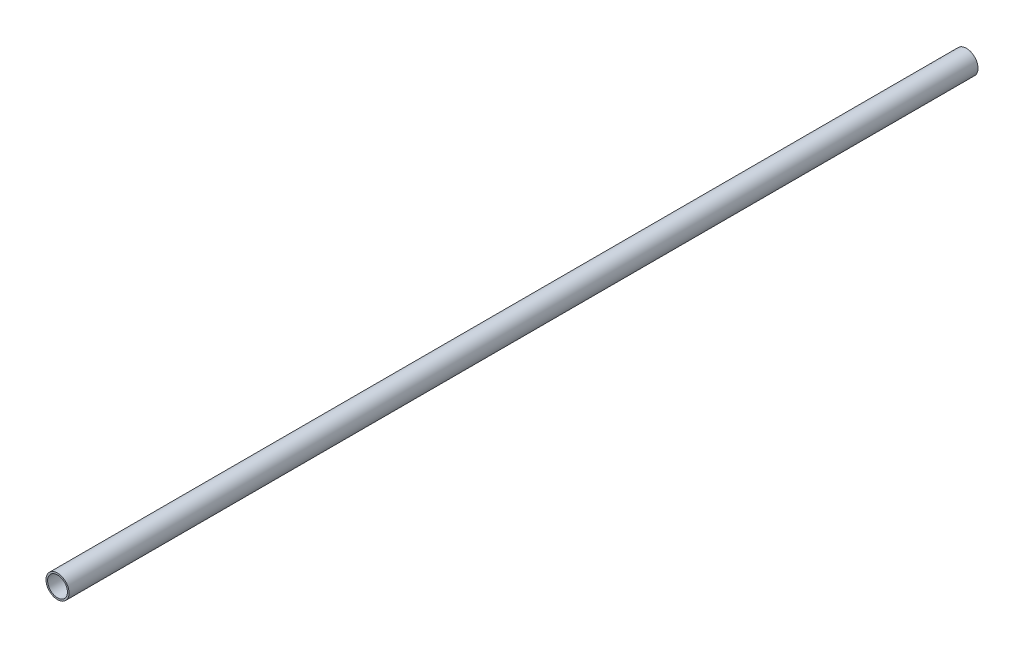
from build123d import *

# Parameters (mm, degrees)
SKETCH1_R           = 6.35
SKETCH1_R_2         = 5.461
BOSS_EXTRUDE1_DEPTH = 500


with BuildPart() as part:
    # Sketch1 → Boss-Extrude1 (new body)
    with BuildSketch(Plane.XY):
        Circle(SKETCH1_R)
        Circle(SKETCH1_R_2, mode=Mode.SUBTRACT)
    extrude(amount=BOSS_EXTRUDE1_DEPTH)


solid = part.part
